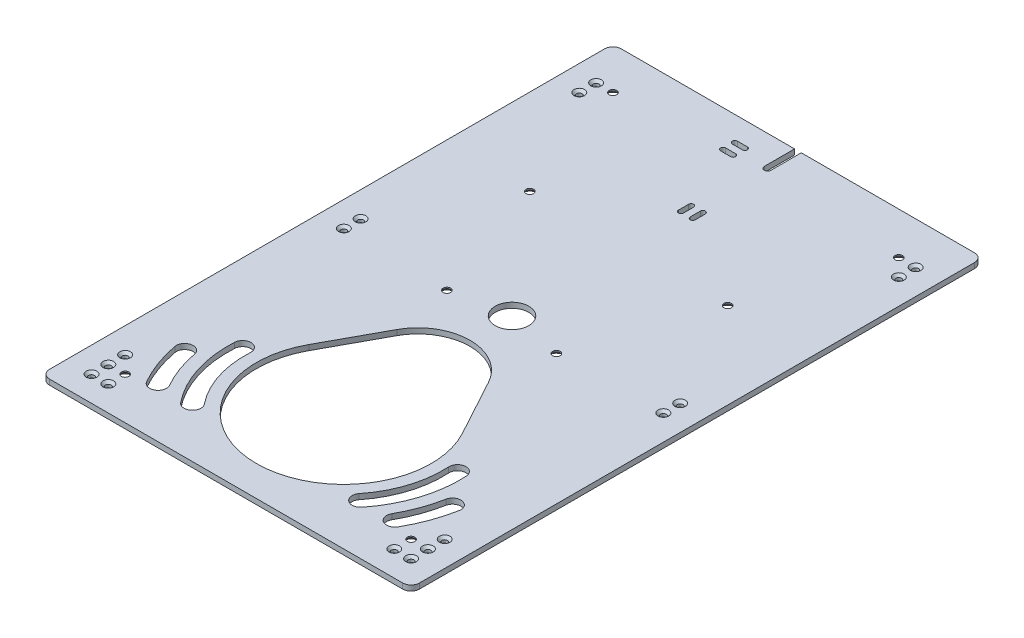
from build123d import *

# Parameters (mm, degrees)
SKETCH1_W                                       = 220
SKETCH1_H                                       = 340
BOSS_EXTRUDE1_DEPTH                             = 3.175
FILLET1_R                                       = 5
SKETCH2_R                                       = 10
CUT_EXTRUDE1_DEPTH                              = 4.175
CSK_FOR_M3_FLAT_HEAD_MACHINE_SCREW1_D           = 3.4
CSK_FOR_M3_FLAT_HEAD_MACHINE_SCREW1_CSINK_D     = 6.3
CSK_FOR_M3_FLAT_HEAD_MACHINE_SCREW1_CSINK_ANGLE = 90
CSK_FOR_M4_FLAT_HEAD_MACHINE_SCREW1_AT_2_COUNT  = 2
CSK_FOR_M4_FLAT_HEAD_MACHINE_SCREW1_AT_2_PITCH  = 290
CSK_FOR_M4_FLAT_HEAD_MACHINE_SCREW1_AT_3_COUNT  = 2
CSK_FOR_M4_FLAT_HEAD_MACHINE_SCREW1_AT_3_PITCH  = 148.413565465
CSK_FOR_M4_FLAT_HEAD_MACHINE_SCREW1_AT_4_COUNT  = 2
CSK_FOR_M4_FLAT_HEAD_MACHINE_SCREW1_AT_4_PITCH  = 216.016881764
CUT_EXTRUDE2_DEPTH                              = 4.175


with BuildPart() as part:
    # Sketch1 → Boss-Extrude1 (new body)
    with BuildSketch(Plane(origin=(0, 0, 0), x_dir=(1, 0, 0), z_dir=(0, 1, 0))):
        Rectangle(SKETCH1_W, SKETCH1_H)
    extrude(amount=BOSS_EXTRUDE1_DEPTH)

    # Fillet1
    fillet1_edges = [part.edges().sort_by_distance(p)[0] for p in [
        (-110, 1.5875, -170),
        (110, 1.5875, -170),
        (110, 1.5875, 170),
        (-110, 1.5875, 170),
    ]]
    fillet(fillet1_edges, radius=FILLET1_R)

    # Sketch2 → Cut-Extrude1 (cut, through all)
    with BuildSketch(Plane(origin=(0, 3.175, 0), x_dir=(1, 0, 0), z_dir=(0, 1, 0))):
        Circle(SKETCH2_R)
        with BuildLine():
            Line((-27.196280021, -41.167293162), (-45.681234259, -75.155989926))
            ThreePointArc((-45.681234259, -75.155989926), (0, -152), (45.681234259, -75.155989926))
            Line((45.681234259, -75.155989926), (27.196280021, -41.167293162))
            ThreePointArc((27.196280021, -41.167293162), (0, -25), (-27.196280021, -41.167293162))
        make_face()
        with BuildLine():
            Line((2, 170), (2, 152))
            ThreePointArc((2, 152), (0, 150), (-2, 152))
            Line((-2, 152), (-2, 170))
            ThreePointArc((-2, 170), (0, 172), (2, 170))
        make_face()
        with BuildLine():
            Line((-2, 110), (-2, 104))
            ThreePointArc((-2, 104), (-3.5, 102.5), (-5, 104))
            Line((-5, 104), (-5, 110))
            ThreePointArc((-5, 110), (-3.5, 111.5), (-2, 110))
        make_face()
        with BuildLine():
            Line((2, 110), (2, 104))
            ThreePointArc((2, 104), (3.5, 102.5), (5, 104))
            Line((5, 104), (5, 110))
            ThreePointArc((5, 110), (3.5, 111.5), (2, 110))
        make_face()
        with BuildLine():
            Line((-23, 157), (-17, 157))
            ThreePointArc((-17, 157), (-15.5, 155.5), (-17, 154))
            Line((-17, 154), (-23, 154))
            ThreePointArc((-23, 154), (-24.5, 155.5), (-23, 157))
        make_face()
        with BuildLine():
            Line((-23, 147), (-17, 147))
            ThreePointArc((-17, 147), (-15.5, 148.5), (-17, 150))
            Line((-17, 150), (-23, 150))
            ThreePointArc((-23, 150), (-24.5, 148.5), (-23, 147))
        make_face()
    extrude(amount=-CUT_EXTRUDE1_DEPTH, mode=Mode.SUBTRACT)

    # CSK for M3 Flat Head Machine Screw1 (through all)
    with Locations(Plane(origin=(0, 3.175, 0), x_dir=(-1, 0, 0), z_dir=(0, 1, 0))):
        with Locations((85, 155), (95, 155), (95, 145), (95, 135), (95, 5), (95, -5), (95, -135), (95, -145)):
            csk_for_m3_flat_head_machine_screw1 = CounterSinkHole(CSK_FOR_M3_FLAT_HEAD_MACHINE_SCREW1_D / 2, CSK_FOR_M3_FLAT_HEAD_MACHINE_SCREW1_CSINK_D / 2, counter_sink_angle=CSK_FOR_M3_FLAT_HEAD_MACHINE_SCREW1_CSINK_ANGLE)

    # Mirror3: CSK for M3 Flat Head Machine Screw1 across plane
    add(csk_for_m3_flat_head_machine_screw1.mirror(Plane(origin=(0, 0, 0), x_dir=(0, 0, 1), z_dir=(1, 0, 0))), mode=Mode.SUBTRACT)

    # Sketch5 → CSK for M4 Flat Head Machine Screw1 (revolve, cut)
    with BuildSketch(Plane(origin=(85, 0, 145), x_dir=(0, 0, -1), z_dir=(1, 0, 0))):
        Polygon((0, 0), (0, 3.175), (2.25, 3.175), (2.25, 2.45), (4.7, 0), align=None)
    csk_for_m4_flat_head_machine_screw1 = revolve(axis=Axis((85, -6.35, 145), (0, 1, 0)), mode=Mode.SUBTRACT)

    # CSK for M4 Flat Head Machine Screw1 at 2: CSK for M4 Flat Head Machine Screw1 ×2
    with Locations(*[(0, 0, -i * CSK_FOR_M4_FLAT_HEAD_MACHINE_SCREW1_AT_2_PITCH) for i in range(1, CSK_FOR_M4_FLAT_HEAD_MACHINE_SCREW1_AT_2_COUNT)]):
        add(csk_for_m4_flat_head_machine_screw1, mode=Mode.SUBTRACT)

    # CSK for M4 Flat Head Machine Screw1 at 3: CSK for M4 Flat Head Machine Screw1 ×2
    with Locations(*[Vector(-0.353361448, 0, -0.935486872) * (i * CSK_FOR_M4_FLAT_HEAD_MACHINE_SCREW1_AT_3_PITCH) for i in range(1, CSK_FOR_M4_FLAT_HEAD_MACHINE_SCREW1_AT_3_COUNT)]):
        add(csk_for_m4_flat_head_machine_screw1, mode=Mode.SUBTRACT)

    # CSK for M4 Flat Head Machine Screw1 at 4: CSK for M4 Flat Head Machine Screw1 ×2
    with Locations(*[Vector(-0.12138781, 0, -0.992605158) * (i * CSK_FOR_M4_FLAT_HEAD_MACHINE_SCREW1_AT_4_PITCH) for i in range(1, CSK_FOR_M4_FLAT_HEAD_MACHINE_SCREW1_AT_4_COUNT)]):
        add(csk_for_m4_flat_head_machine_screw1, mode=Mode.SUBTRACT)

    # Mirror4: CSK for M4 Flat Head Machine Screw1 across plane
    add(csk_for_m4_flat_head_machine_screw1.mirror(Plane(origin=(0, 0, 0), x_dir=(0, 0, 1), z_dir=(1, 0, 0))), mode=Mode.SUBTRACT)

    # Mirror4 copy 1 sketch → Mirror4 copy 1 (revolve, cut)
    with BuildSketch(Plane(origin=(-85, 0, -145), x_dir=(0, 0, -1), z_dir=(-1, 0, 0))):
        Polygon((0, 0), (0, -3.175), (2.25, -3.175), (2.25, -2.45), (4.7, 0), align=None)
    revolve(axis=Axis((-85, -6.35, -145), (0, -1, 0)), mode=Mode.SUBTRACT)

    # Mirror4 copy 2 sketch → Mirror4 copy 2 (revolve, cut)
    with BuildSketch(Plane(origin=(-32.556367665, 0, 6.161057907), x_dir=(0, 0, -1), z_dir=(-1, 0, 0))):
        Polygon((0, 0), (0, -3.175), (2.25, -3.175), (2.25, -2.45), (4.7, 0), align=None)
    revolve(axis=Axis((-32.556367665, -6.35, 6.161057907), (0, -1, 0)), mode=Mode.SUBTRACT)

    # Mirror4 copy 3 sketch → Mirror4 copy 3 (revolve, cut)
    with BuildSketch(Plane(origin=(-58.778183832, 0, -69.419471047), x_dir=(0, 0, -1), z_dir=(-1, 0, 0))):
        Polygon((0, 0), (0, -3.175), (2.25, -3.175), (2.25, -2.45), (4.7, 0), align=None)
    revolve(axis=Axis((-58.778183832, -6.35, -69.419471047), (0, -1, 0)), mode=Mode.SUBTRACT)

    # Sketch7 → Cut-Extrude2 (cut, through all)
    with BuildSketch(Plane(origin=(0, 3.175, 0), x_dir=(1, 0, 0), z_dir=(0, 1, 0))):
        with BuildLine():
            ThreePointArc((53.863107736, -143.125), (65.742634228, -120.950084602), (68.883402568, -95.99040518))
            ThreePointArc((68.883402568, -95.99040518), (63.601301308, -91.289404619), (58.900300747, -96.571505879))
            ThreePointArc((58.900300747, -96.571505879), (56.214716224, -117.913840457), (46.056860238, -136.875))
            ThreePointArc((46.056860238, -136.875), (46.834983987, -143.903123749), (53.863107736, -143.125))
        make_face()
        with BuildLine():
            ThreePointArc((74.685476761, -114.074074074), (71.35648023, -126.158224886), (66.086566204, -137.530864198))
            ThreePointArc((66.086566204, -137.530864198), (67.965230809, -144.347800408), (74.78216702, -142.469135802))
            ThreePointArc((74.78216702, -142.469135802), (80.745490786, -129.600096582), (84.512513176, -115.925925926))
            ThreePointArc((84.512513176, -115.925925926), (80.524920894, -110.086481792), (74.685476761, -114.074074074))
        make_face()
    cut_extrude2 = extrude(amount=-CUT_EXTRUDE2_DEPTH, mode=Mode.SUBTRACT)

    # Mirror5: Cut-Extrude2 across plane
    add(cut_extrude2.mirror(Plane(origin=(0, 0, 0), x_dir=(0, 0, 1), z_dir=(1, 0, 0))), mode=Mode.SUBTRACT)


solid = part.part
